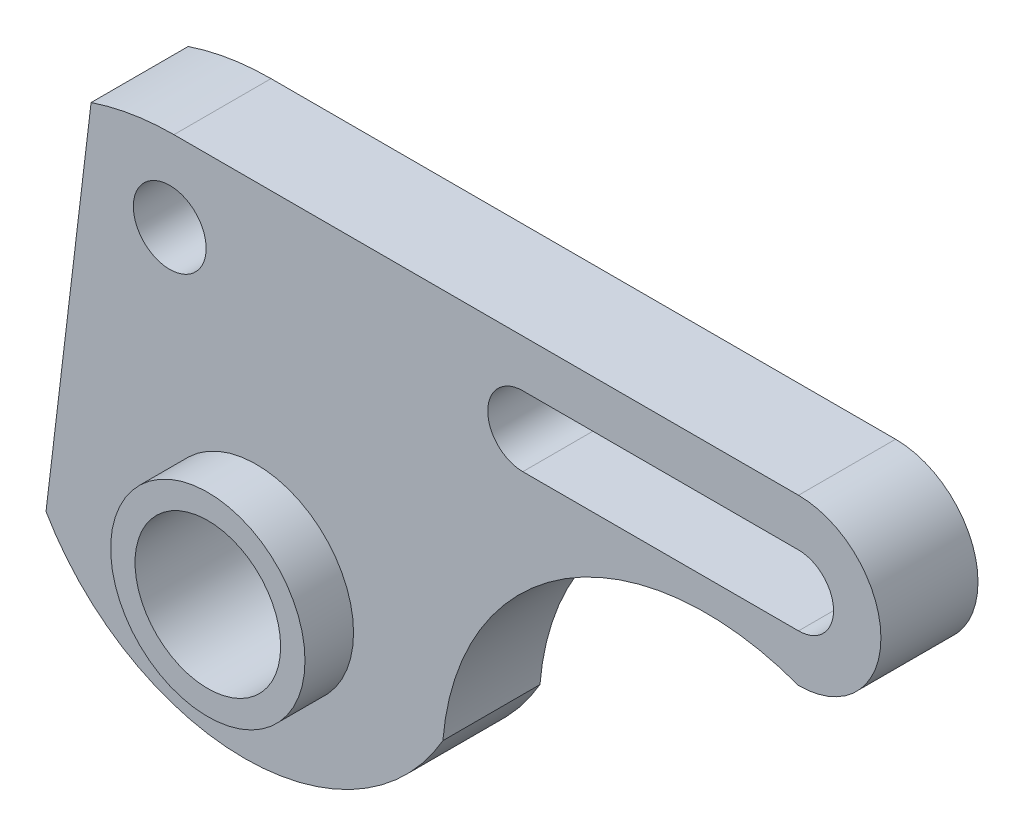
from build123d import *

# Parameters (mm, degrees)
BOSS_EXTRUDE2_DEPTH = 20
SKETCH3_R           = 7.5
CUT_EXTRUDE1_DEPTH  = 20
SKETCH4_R           = 20.021959316
BOSS_EXTRUDE3_DEPTH = 10
SKETCH5_R           = 15
CUT_EXTRUDE3_DEPTH  = 40


with BuildPart() as part:
    # Sketch1 → Boss-Extrude2 (new body)
    with BuildSketch(Plane.XY):
        with BuildLine():
            Line((111.70070007, 55.403547234), (-16.978506411, 55.403547234))
            ThreePointArc((-16.978506411, 55.403547234), (-25.627613379, 54.698491332), (-34.048339635, 52.601940713))
            Line((-34.048339635, 52.601940713), (-43.339871627, -25.020956816))
            ThreePointArc((-43.339871627, -25.020956816), (-2.457415402, -48.618782438), (38.425040824, -25.020956816))
            ThreePointArc((38.425040824, -25.020956816), (63.518057264, 16.418071125), (111.70070007, 21.446534413))
            ThreePointArc((111.70070007, 21.446534413), (128.67920648, 38.425040824), (111.70070007, 55.403547234))
        make_face()
    extrude(amount=BOSS_EXTRUDE2_DEPTH)

    # Sketch3 → Cut-Extrude1 (cut)
    with BuildSketch(Plane.XY.offset(20)):
        with Locations((-17.848919817, 38.425040824)):
            Circle(SKETCH3_R)
        with BuildLine():
            Line((54.895644648, 45.643601072), (111.70070007, 45.643601072))
            ThreePointArc((111.70070007, 45.643601072), (118.919260318, 38.425040824), (111.70070007, 31.206480576))
            Line((111.70070007, 31.206480576), (54.895644648, 31.206480576))
            ThreePointArc((54.895644648, 31.206480576), (47.6770844, 38.425040824), (54.895644648, 45.643601072))
        make_face()
    extrude(amount=-CUT_EXTRUDE1_DEPTH, mode=Mode.SUBTRACT)

    # Sketch4 → Boss-Extrude3 (add)
    with BuildSketch(Plane.XY.offset(20)):
        with Locations((0, -14.946583433)):
            Circle(SKETCH4_R)
    extrude(amount=BOSS_EXTRUDE3_DEPTH)

    # Sketch5 → Cut-Extrude3 (cut)
    with BuildSketch(Plane.XY.offset(30)):
        with Locations((0, -14.946583433)):
            Circle(SKETCH5_R)
    extrude(amount=-CUT_EXTRUDE3_DEPTH, mode=Mode.SUBTRACT)


solid = part.part
